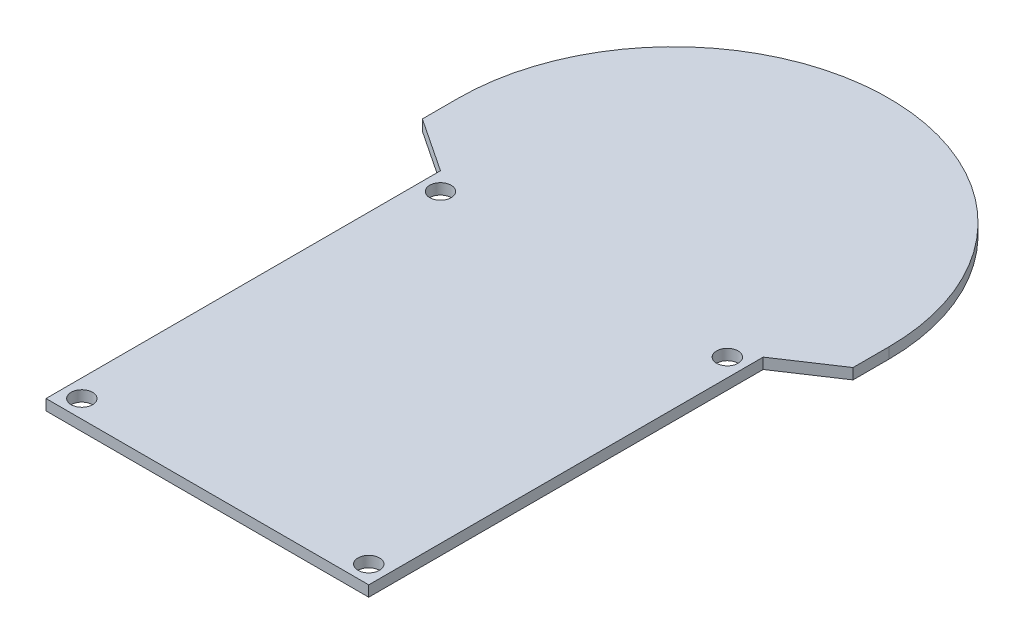
from build123d import *

# Parameters (mm, degrees)
BOSS_EXTRUDE1_DEPTH = 1.5
SKETCH2_R           = 1.5
CUT_EXTRUDE1_DEPTH  = 2.5


with BuildPart() as part:
    # Sketch1 → Boss-Extrude1 (new body)
    with BuildSketch(Plane(origin=(0, 0, 0), x_dir=(1, 0, 0), z_dir=(0, 1, 0))):
        with BuildLine():
            Line((-45.021006533, 42.5), (-45.021006533, 37.5))
            Line((-45.021006533, 37.5), (-37.5, 32.5))
            Line((-37.5, 32.5), (-37.5, -22.5))
            Line((-37.5, -22.5), (7.5, -22.5))
            Line((7.5, -22.5), (7.5, 32.5))
            Line((7.5, 32.5), (15.021006533, 37.5))
            Line((15.021006533, 37.5), (15.021006533, 42.5))
            ThreePointArc((15.021006533, 42.5), (-15, 72.521006533), (-45.021006533, 42.5))
        make_face()
    extrude(amount=BOSS_EXTRUDE1_DEPTH)

    # Sketch2 → Cut-Extrude1 (cut, through all)
    with BuildSketch(Plane(origin=(0, 1.5, 0), x_dir=(1, 0, 0), z_dir=(0, 1, 0))):
        with Locations((-35, 30)):
            Circle(SKETCH2_R)
        with Locations((-35, -20)):
            Circle(SKETCH2_R)
        with Locations((5, -20)):
            Circle(SKETCH2_R)
        with Locations((5, 30)):
            Circle(SKETCH2_R)
    extrude(amount=-CUT_EXTRUDE1_DEPTH, mode=Mode.SUBTRACT)


solid = part.part
